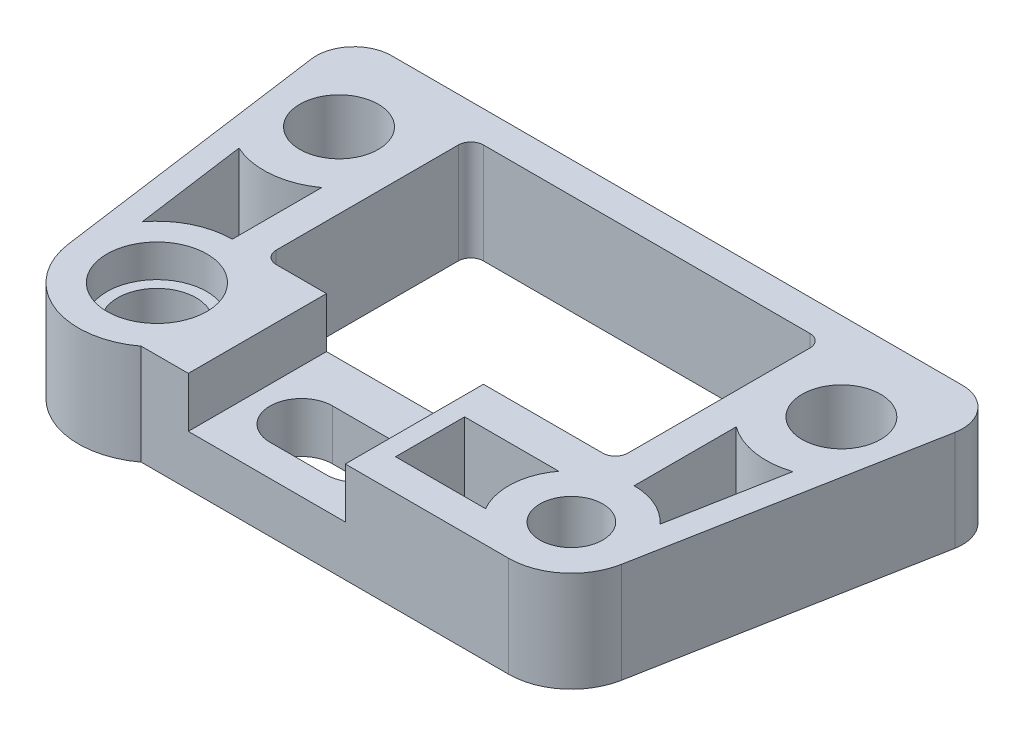
from build123d import *

# Parameters (mm, degrees)
SKETCH3_R           = 3.96875
SKETCH3_R_2         = 3.175
BOSS_EXTRUDE4_DEPTH = 10.16
SKETCH5_W           = 15.875
SKETCH5_H           = 13.97
CUT_EXTRUDE3_DEPTH  = 5.08
FILLET1_R           = 3.81
SKETCH6_R           = 5.05
CUT_EXTRUDE4_DEPTH  = 3.3


with BuildPart() as part:
    # Sketch3 → Boss-Extrude4 (new body)
    with BuildSketch(Plane(origin=(0, 0, 0), x_dir=(1, 0, 0), z_dir=(0, 1, 0))):
        with BuildLine():
            Line((54.2925, 31.75), (-12.3825, 31.75))
            Line((-12.3825, 31.75), (-7.863361559, -1.082336008))
            ThreePointArc((-7.863361559, -1.082336008), (-3.056289676, -7.325503373), (4.7625, -6.35))
            Line((4.7625, -6.35), (41.91, -6.35))
            ThreePointArc((41.91, -6.35), (45.967580476, -4.884520517), (48.152310263, -1.164501002))
            Line((48.152310263, -1.164501002), (54.2925, 31.75))
        make_face()
        Circle(SKETCH3_R, mode=Mode.SUBTRACT)
        with Locations((-4.445, 22.86)):
            Circle(SKETCH3_R, mode=Mode.SUBTRACT)
        with Locations((46.355, 22.86)):
            Circle(SKETCH3_R, mode=Mode.SUBTRACT)
        with Locations((41.91, 0)):
            Circle(SKETCH3_R_2, mode=Mode.SUBTRACT)
        with BuildLine():
            Line((38.735, 8.89), (38.735, 27.305))
            ThreePointArc((38.735, 27.305), (38.363025612, 28.203025612), (37.465, 28.575))
            Line((37.465, 28.575), (4.445, 28.575))
            ThreePointArc((4.445, 28.575), (3.546974388, 28.203025612), (3.175, 27.305))
            Line((3.175, 27.305), (3.175, 8.89))
            ThreePointArc((3.175, 8.89), (3.546974388, 7.991974388), (4.445, 7.62))
            Line((4.445, 7.62), (37.465, 7.62))
            ThreePointArc((37.465, 7.62), (38.363025612, 7.991974388), (38.735, 8.89))
        make_face(mode=Mode.SUBTRACT)
        with BuildLine():
            Line((20.32, 3.175), (14.605, 3.175))
            ThreePointArc((14.605, 3.175), (11.43, 0), (14.605, -3.175))
            Line((14.605, -3.175), (20.32, -3.175))
            ThreePointArc((20.32, -3.175), (22.498043553, -2.310140965), (23.489504023, -0.186733089))
            Line((23.489504023, -0.186733089), (21.228562514, 3.04222602))
            ThreePointArc((21.228562514, 3.04222602), (20.779106407, 3.141631154), (20.32, 3.175))
        make_face(mode=Mode.SUBTRACT)
        with BuildLine():
            Line((46.58698696, 4.295147609), (48.697586564, 15.60902157))
            ThreePointArc((48.697586564, 15.60902157), (45.177345011, 15.331552037), (41.91, 16.670785591))
            Line((41.91, 16.670785591), (41.91, 6.35))
            ThreePointArc((41.91, 6.35), (44.464242812, 5.81363429), (46.58698696, 4.295147609))
        make_face(mode=Mode.SUBTRACT)
        with BuildLine():
            Line((-6.080523252, 4.592563226), (-7.642900683, 15.943510195))
            ThreePointArc((-7.642900683, 15.943510195), (-3.723164456, 15.274266453), (0, 16.670785591))
            Line((0, 16.670785591), (0, 7.62))
            ThreePointArc((0, 7.62), (-3.396252951, 6.82128037), (-6.080523252, 4.592563226))
        make_face(mode=Mode.SUBTRACT)
        with BuildLine():
            Line((36.410738686, -3.175), (27.305, -3.175))
            Line((27.305, -3.175), (27.305, 3.81))
            Line((27.305, 3.81), (36.83, 3.81))
            ThreePointArc((36.83, 3.81), (35.571407985, 0.380461907), (36.410738686, -3.175))
        make_face(mode=Mode.SUBTRACT)
    extrude(amount=BOSS_EXTRUDE4_DEPTH)

    # Sketch5 → Cut-Extrude3 (cut)
    with BuildSketch(Plane(origin=(0, 10.16, 0), x_dir=(1, 0, 0), z_dir=(0, 1, 0))):
        with Locations((17.4625, 0.635)):
            Rectangle(SKETCH5_W, SKETCH5_H)
    extrude(amount=-CUT_EXTRUDE3_DEPTH, mode=Mode.SUBTRACT)

    # Fillet1
    fillet1_edges = [part.edges().sort_by_distance(p)[0] for p in [
        (-12.3825, 5.08, -31.75),
        (54.2925, 5.08, -31.75),
    ]]
    fillet(fillet1_edges, radius=FILLET1_R)

    # Sketch6 → Cut-Extrude4 (cut)
    with BuildSketch(Plane(origin=(0, 10.16, 0), x_dir=(1, 0, 0), z_dir=(0, 1, 0))):
        Circle(SKETCH6_R)
    extrude(amount=-CUT_EXTRUDE4_DEPTH, mode=Mode.SUBTRACT)


solid = part.part
